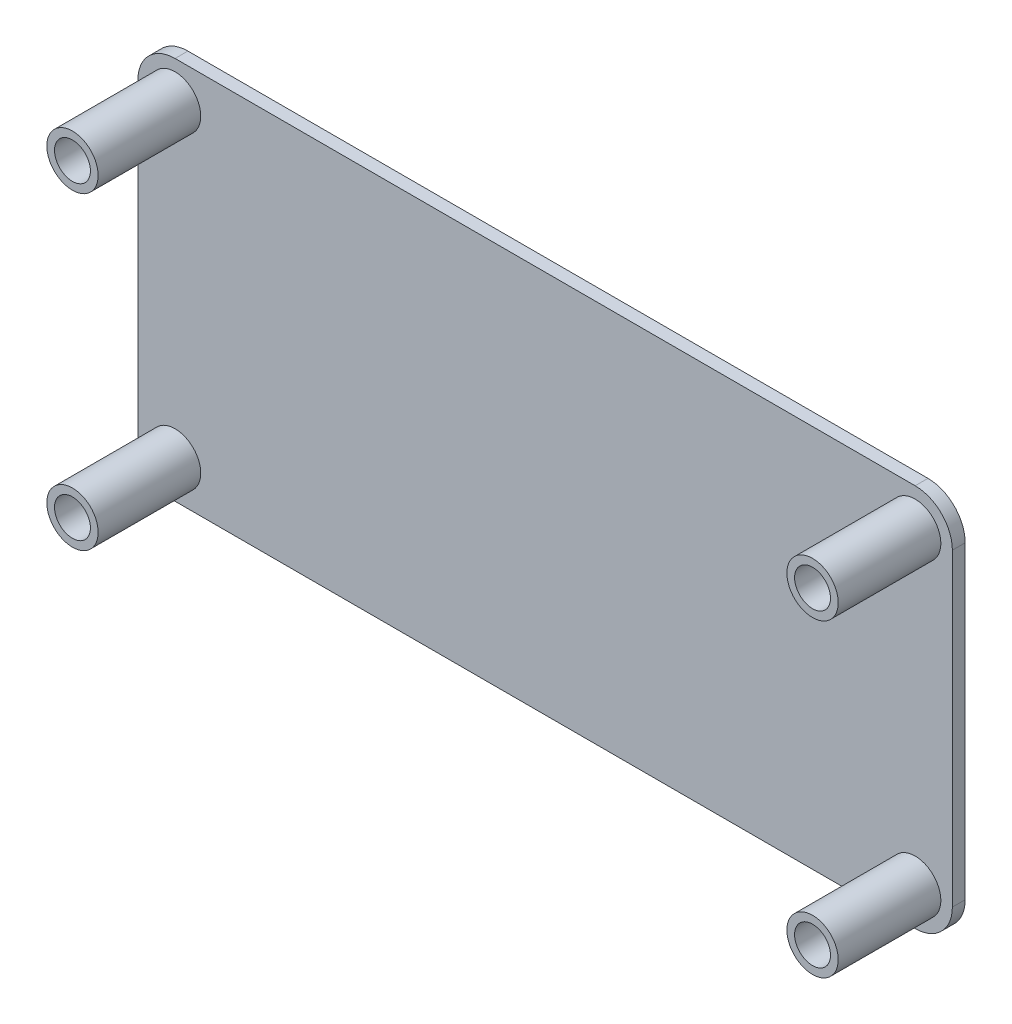
from build123d import *

# Parameters (mm, degrees)
EXTRUDE_1_DEPTH = 1
SKETCH_3_R      = 2
SKETCH_3_R_2    = 1.4
EXTRUDE_3_DEPTH = 9


with BuildPart() as part:
    # 草图1 → 凸台-拉伸1 (new body)
    with BuildSketch(Plane.XY):
        with BuildLine():
            Line((0, -2.9), (57.7, -2.9))
            ThreePointArc((57.7, -2.9), (59.750609665, -2.050609665), (60.6, 0))
            Line((60.6, 0), (60.6, 24.1))
            ThreePointArc((60.6, 24.1), (59.750609665, 26.150609665), (57.7, 27))
            Line((57.7, 27), (0, 27))
            ThreePointArc((0, 27), (-2.050609665, 26.150609665), (-2.9, 24.1))
            Line((-2.9, 24.1), (-2.9, 0))
            ThreePointArc((-2.9, 0), (-2.050609665, -2.050609665), (0, -2.9))
        make_face()
    extrude(amount=EXTRUDE_1_DEPTH)

    # 草图3 → 凸台-拉伸3 (add)
    with BuildSketch(Plane.XY):
        Circle(SKETCH_3_R)
        Circle(SKETCH_3_R_2, mode=Mode.SUBTRACT)
        with Locations((0, 24.1)):
            Circle(SKETCH_3_R)
        with Locations((0, 24.1)):
            Circle(SKETCH_3_R_2, mode=Mode.SUBTRACT)
        with Locations((57.7, 0)):
            Circle(SKETCH_3_R)
        with Locations((57.7, 0)):
            Circle(SKETCH_3_R_2, mode=Mode.SUBTRACT)
        with Locations((57.7, 24.1)):
            Circle(SKETCH_3_R)
        with Locations((57.7, 24.1)):
            Circle(SKETCH_3_R_2, mode=Mode.SUBTRACT)
    extrude(amount=EXTRUDE_3_DEPTH)


solid = part.part
